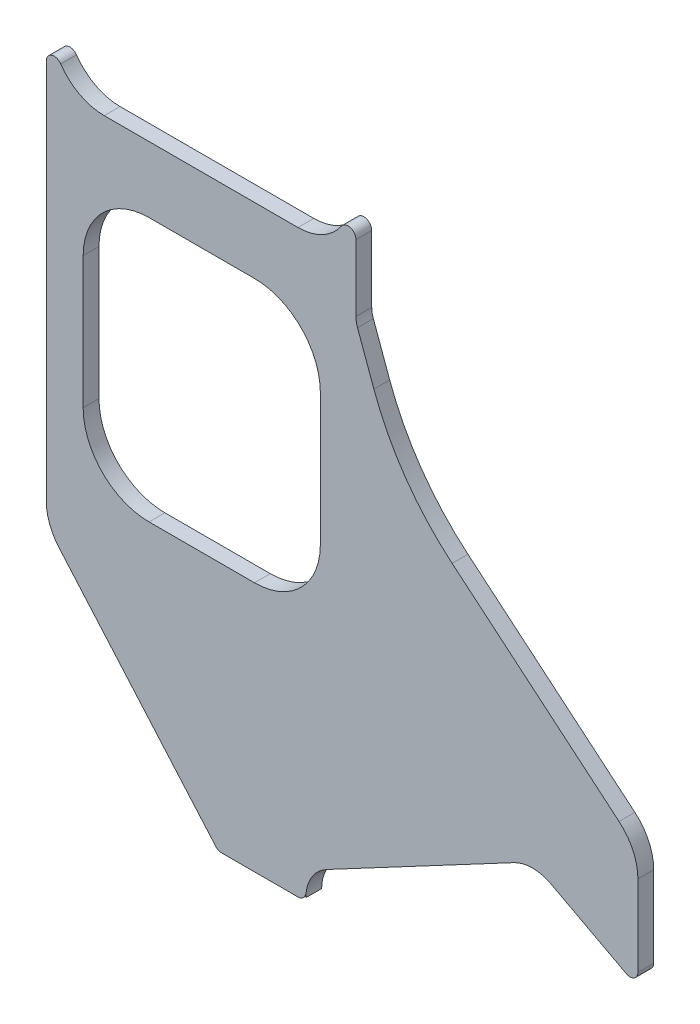
from build123d import *

# Parameters (mm, degrees)
EXTRUDE1_DEPTH = 6


with BuildPart() as part:
    # Sketch1 → Extrude1 (new body)
    with BuildSketch(Plane.XY):
        with BuildLine():
            Line((-7.042073442, -3.744336867), (-78.042073442, -41.495706515))
            ThreePointArc((-78.042073442, -41.495706515), (-83.857509511, -47.014349285), (-86, -54.739920408))
            Line((-86, -54.739920408), (-86, -53))
            ThreePointArc((-86, -53), (-86.878679656, -55.121320344), (-89, -56))
            Line((-89, -56), (-117.936315897, -56))
            ThreePointArc((-117.936315897, -56), (-119.180395625, -55.729883813), (-120.200444638, -54.968177087))
            Line((-120.200444638, -54.968177087), (-179.594191604, 13.35651301))
            ThreePointArc((-179.594191604, 13.35651301), (-183.233443785, 19.473545965), (-184.5, 26.47769359))
            Line((-184.5, 26.47769359), (-184.5, 171.038518603))
            ThreePointArc((-184.5, 171.038518603), (-182.384651737, 173.905117861), (-179.02173913, 172.729146611))
            ThreePointArc((-179.02173913, 172.729146611), (-171.842990213, 166.316433225), (-162.5, 164))
            Line((-162.5, 164), (-89, 164))
            ThreePointArc((-89, 164), (-79.657009787, 166.316433225), (-72.47826087, 172.729146611))
            ThreePointArc((-72.47826087, 172.729146611), (-69.115348263, 173.905117861), (-67, 171.038518603))
            Line((-67, 171.038518603), (-67, 145.763269807))
            ThreePointArc((-67, 145.763269807), (-66.84807753, 144.02678803), (-66.396926208, 142.343068374))
            Line((-66.396926208, 142.343068374), (-60.19025019, 125.290366164))
            ThreePointArc((-60.19025019, 125.290366164), (-48.13619254, 102.134736861), (-30.49974908, 82.887936184))
            Line((-30.49974908, 82.887936184), (32.855752194, 29.726358433))
            ThreePointArc((32.855752194, 29.726358433), (38.126155741, 22.857834805), (40, 14.40546957))
            Line((40, 14.40546957), (40, -16.275538819))
            ThreePointArc((40, -16.275538819), (38.545114225, -18.847040722), (35.591585312, -18.924381598))
            Line((35.591585312, -18.924381598), (7.042073442, -3.744336867))
            ThreePointArc((7.042073442, -3.744336867), (0, -1.98855076), (-7.042073442, -3.744336867))
        make_face()
        with BuildLine():
            Line((-145.5, 139), (-105.5, 139))
            ThreePointArc((-105.5, 139), (-87.82233047, 131.67766953), (-80.5, 114))
            Line((-80.5, 114), (-80.5, 64))
            ThreePointArc((-80.5, 64), (-87.82233047, 46.32233047), (-105.5, 39))
            Line((-105.5, 39), (-145.5, 39))
            ThreePointArc((-145.5, 39), (-163.17766953, 46.32233047), (-170.5, 64))
            Line((-170.5, 64), (-170.5, 114))
            ThreePointArc((-170.5, 114), (-163.17766953, 131.67766953), (-145.5, 139))
        make_face(mode=Mode.SUBTRACT)
    extrude(amount=EXTRUDE1_DEPTH)


solid = part.part
